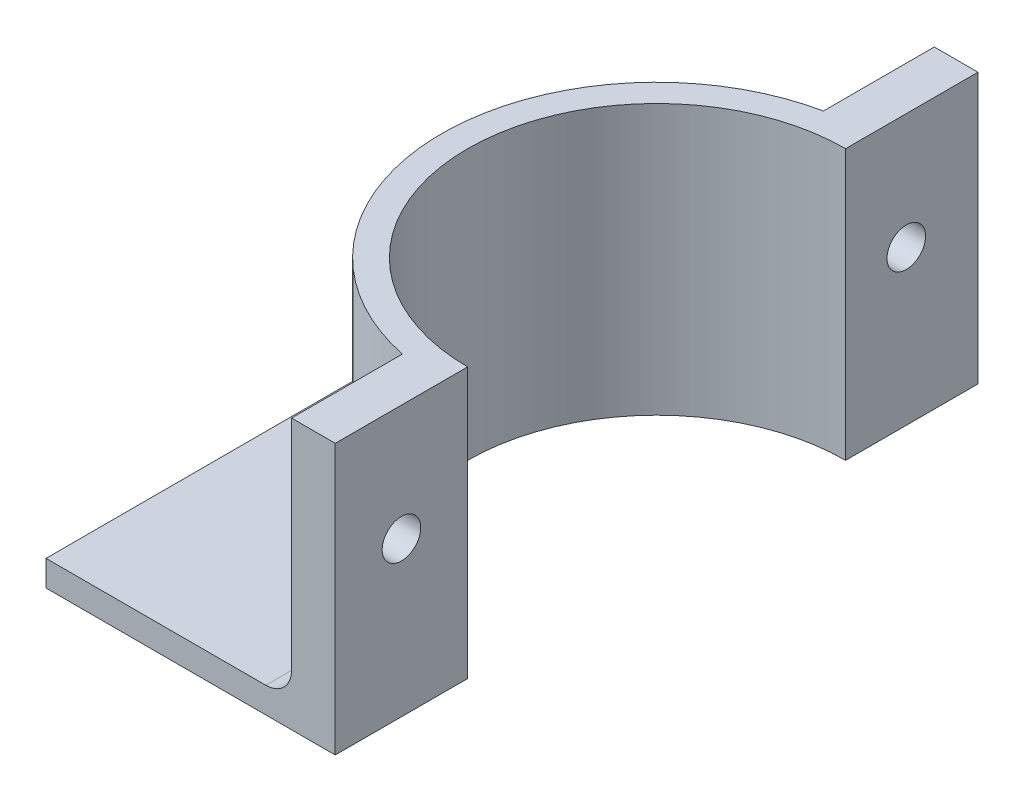
from build123d import *

# Parameters (mm, degrees)
BOSS_EXTRUDE14_DEPTH = 2.54
BOSS_EXTRUDE15_DEPTH = 26.67
SKETCH5_R            = 1.905
CUT_EXTRUDE12_DEPTH  = 75.565873729
FILLET3_R            = 2.54


with BuildPart() as part:
    # Sketch3 → Boss-Extrude14 (new body)
    with BuildSketch(Plane(origin=(0, 0, 0), x_dir=(1, 0, 0), z_dir=(0, 1, 0))):
        with BuildLine():
            Line((0, 63.5), (0, 0))
            Line((0, 0), (24.257, 0))
            Line((24.257, 0), (24.257, 10.953386454))
            ThreePointArc((24.257, 10.953386454), (7.334843244, 31.75), (24.257, 52.546613546))
            Line((24.257, 52.546613546), (24.257, 63.5))
            Line((24.257, 63.5), (0, 63.5))
        make_face()
    extrude(amount=BOSS_EXTRUDE14_DEPTH)

    # Sketch3_18 → Boss-Extrude15 (add)
    with BuildSketch(Plane(origin=(0, 0, 0), x_dir=(1, 0, 0), z_dir=(0, 1, 0))):
        with BuildLine():
            Line((24.257, 10.953386454), (24.257, 0))
            Line((24.257, 0), (28.575, 0))
            Line((28.575, 0), (28.575, 13.081))
            ThreePointArc((28.575, 13.081), (9.906, 31.75), (28.575, 50.419))
            Line((28.575, 50.419), (28.575, 63.5))
            Line((28.575, 63.5), (24.257, 63.5))
            Line((24.257, 63.5), (24.257, 52.546613546))
            ThreePointArc((24.257, 52.546613546), (7.334843244, 31.75), (24.257, 10.953386454))
        make_face()
    extrude(amount=BOSS_EXTRUDE15_DEPTH)

    # Sketch5 → Cut-Extrude12 (cut, through all)
    with BuildSketch(Plane(origin=(0, 0, 0), x_dir=(0, 0, -1), z_dir=(1, 0, 0))):
        with Locations((6.5405, 15.24)):
            Circle(SKETCH5_R)
        with Locations((56.41762459, 15.24)):
            Circle(SKETCH5_R)
    extrude(amount=CUT_EXTRUDE12_DEPTH, mode=Mode.SUBTRACT)

    # Fillet3
    fillet3_edges = [part.edges().sort_by_distance(p)[0] for p in [
        (24.257, 2.54, -58.023306773),
        (7.334843244, 2.54, -31.75),
        (24.257, 2.54, -5.476693227),
    ]]
    fillet(fillet3_edges, radius=FILLET3_R)


solid = part.part
